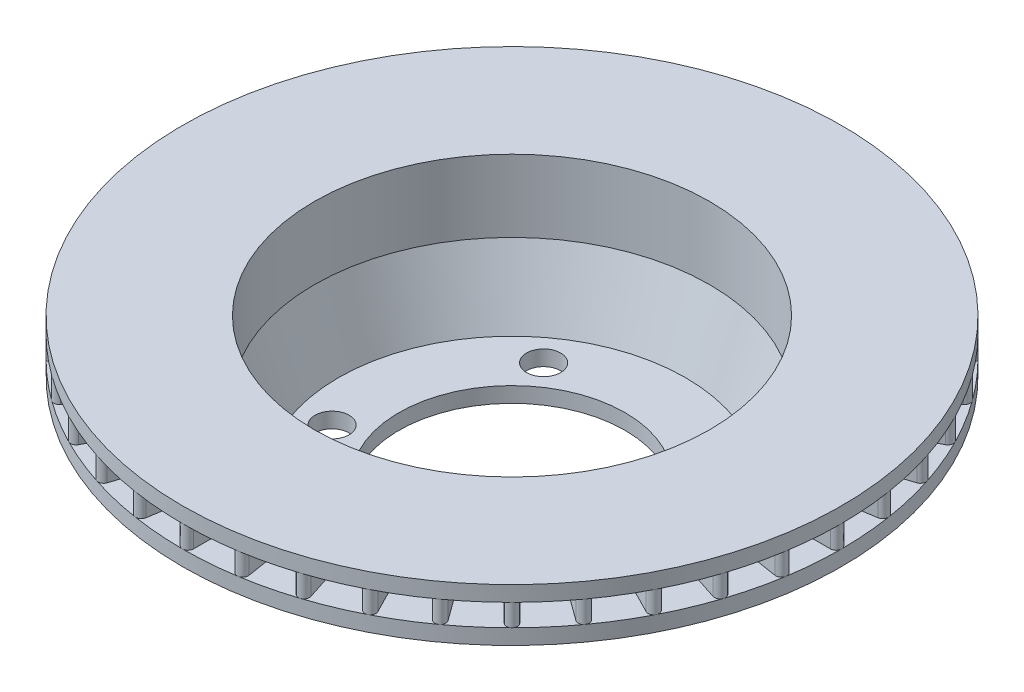
from build123d import *

# Parameters (mm, degrees)
SKETCH1_R                     = 97
BOSS_EXTRUDE1_DEPTH           = 10
BOSS_EXTRUDE1_OTHER_WAY_DEPTH = 37
BOSS_EXTRUDE1_OTHER_WAY_TAPER = 19.3589
SHELL1_T                      = -7
SKETCH2_R                     = 150
SKETCH2_R_2                   = 90
BOSS_EXTRUDE2_DEPTH           = 7
SKETCH3_R                     = 97
SKETCH3_R_2                   = 90
EXTRUDE_THIN1_DEPTH           = 10
SKETCH4_R                     = 150
SKETCH4_R_2                   = 90
BOSS_EXTRUDE3_DEPTH           = 7
BOSS_EXTRUDE4_DEPTH           = 10
CIRPATTERN1_COUNT             = 40
F_15_5_15_5_DIAMETER_HOLE1_D  = 15.5
CIRPATTERN2_COUNT             = 5
FILLET1_R                     = 2
SKETCH11_R                    = 51.5
CUT_EXTRUDE1_DEPTH            = 7


with BuildPart() as part:
    # Sketch1 → Boss-Extrude1 (new body)
    with BuildSketch(Plane(origin=(0, 0, 0), x_dir=(1, 0, 0), z_dir=(0, 1, 0))):
        with Locations(Location((0, 0, 0), (0, 0, 270))):
            Circle(SKETCH1_R)
    extrude(amount=BOSS_EXTRUDE1_DEPTH)

    # Sketch1 → Boss-Extrude1 other way (add)
    with BuildSketch(Plane(origin=(0, 0, 0), x_dir=(1, 0, 0), z_dir=(0, 1, 0))):
        with Locations(Location((0, 0, 0), (0, 0, 270))):
            Circle(SKETCH1_R)
    extrude(amount=-BOSS_EXTRUDE1_OTHER_WAY_DEPTH, taper=BOSS_EXTRUDE1_OTHER_WAY_TAPER)

    # Shell1
    shell1_openings = [part.faces().sort_by_distance(p)[0] for p in [
        (0, 10, 0),
    ]]
    offset(amount=SHELL1_T, openings=shell1_openings, kind=Kind.INTERSECTION)

    # Sketch2 → Boss-Extrude2 (add)
    with BuildSketch(Plane(origin=(0, 10, 0), x_dir=(1, 0, 0), z_dir=(0, 1, 0))):
        with Locations(Location((0, 0, 0), (0, 0, 270))):
            Circle(SKETCH2_R)
        with Locations(Location((0, 0, 0), (0, 0, 270))):
            Circle(SKETCH2_R_2, mode=Mode.SUBTRACT)
    extrude(amount=BOSS_EXTRUDE2_DEPTH)

    # Sketch3 → Extrude-Thin1 (add)
    with BuildSketch(Plane(origin=(0, 17, 0), x_dir=(1, 0, 0), z_dir=(0, 1, 0))):
        Circle(SKETCH3_R)
        Circle(SKETCH3_R_2, mode=Mode.SUBTRACT)
    extrude(amount=EXTRUDE_THIN1_DEPTH)

    # Sketch4 → Boss-Extrude3 (add)
    with BuildSketch(Plane(origin=(0, 27, 0), x_dir=(1, 0, 0), z_dir=(0, 1, 0))):
        with Locations(Location((0, 0, 0), (0, 0, 270))):
            Circle(SKETCH4_R)
        with Locations(Location((0, 0, 0), (0, 0, 270))):
            Circle(SKETCH4_R_2, mode=Mode.SUBTRACT)
    extrude(amount=BOSS_EXTRUDE3_DEPTH)

    # Sketch5 → Revolve1 (revolve)
    with BuildSketch(Plane.XY, mode=Mode.PRIVATE) as revolve1_sk:
        Polygon((97, 27), (97, 17), (107, 17), align=None)
    revolve(revolve1_sk.sketch.rotate(Axis((0, 62.495729326, 0), (0, -1, 0)), 90), axis=Axis((0, 62.495729326, 0), (0, -1, 0)))

    # Sketch6 → Boss-Extrude4 (add)
    with BuildSketch(Plane(origin=(0, 17, 0), x_dir=(1, 0, 0), z_dir=(0, 1, 0))):
        with BuildLine():
            Line((2.5, 147.5), (2.5, 92.5))
            ThreePointArc((2.5, 92.5), (0, 90), (-2.5, 92.5))
            Line((-2.5, 92.5), (-2.5, 147.5))
            ThreePointArc((-2.5, 147.5), (0, 150), (2.5, 147.5))
        make_face()
    boss_extrude4 = extrude(amount=BOSS_EXTRUDE4_DEPTH)

    # CirPattern1: Boss-Extrude4 ×40 about axis
    cirpattern1_axis = Axis((0, 0, 0), (0, 1, 0))
    for i in range(1, CIRPATTERN1_COUNT):
        add(boss_extrude4.rotate(cirpattern1_axis, i * 360 / CIRPATTERN1_COUNT))

    # Ø15.5 (15.5) Diameter Hole1 (through all)
    with Locations(Plane(origin=(0, -37, 0), x_dir=(-1, 0, 0), z_dir=(0, -1, 0))):
        with Locations((0, -65)):
            f_15_5_15_5_diameter_hole1 = Hole(F_15_5_15_5_DIAMETER_HOLE1_D / 2)

    # CirPattern2: Ø15.5 (15.5) Diameter Hole1 ×5 about axis
    cirpattern2_axis = Axis((0, 0, 0), (0, 1, 0))
    for i in range(1, CIRPATTERN2_COUNT):
        add(f_15_5_15_5_diameter_hole1.rotate(cirpattern2_axis, i * 360 / CIRPATTERN2_COUNT), mode=Mode.SUBTRACT)

    # Fillet1
    fillet1_edges = [part.edges().sort_by_distance(p)[0] for p in [
        (0, -37, -84.000068324),
    ]]
    fillet(fillet1_edges, radius=FILLET1_R)

    # Sketch11 → Cut-Extrude1 (cut)
    with BuildSketch(Plane.XZ.offset(37)):
        with Locations(Location((0, 0, 0), (0, 0, 270))):
            Circle(SKETCH11_R)
    extrude(amount=-CUT_EXTRUDE1_DEPTH, mode=Mode.SUBTRACT)


solid = part.part
